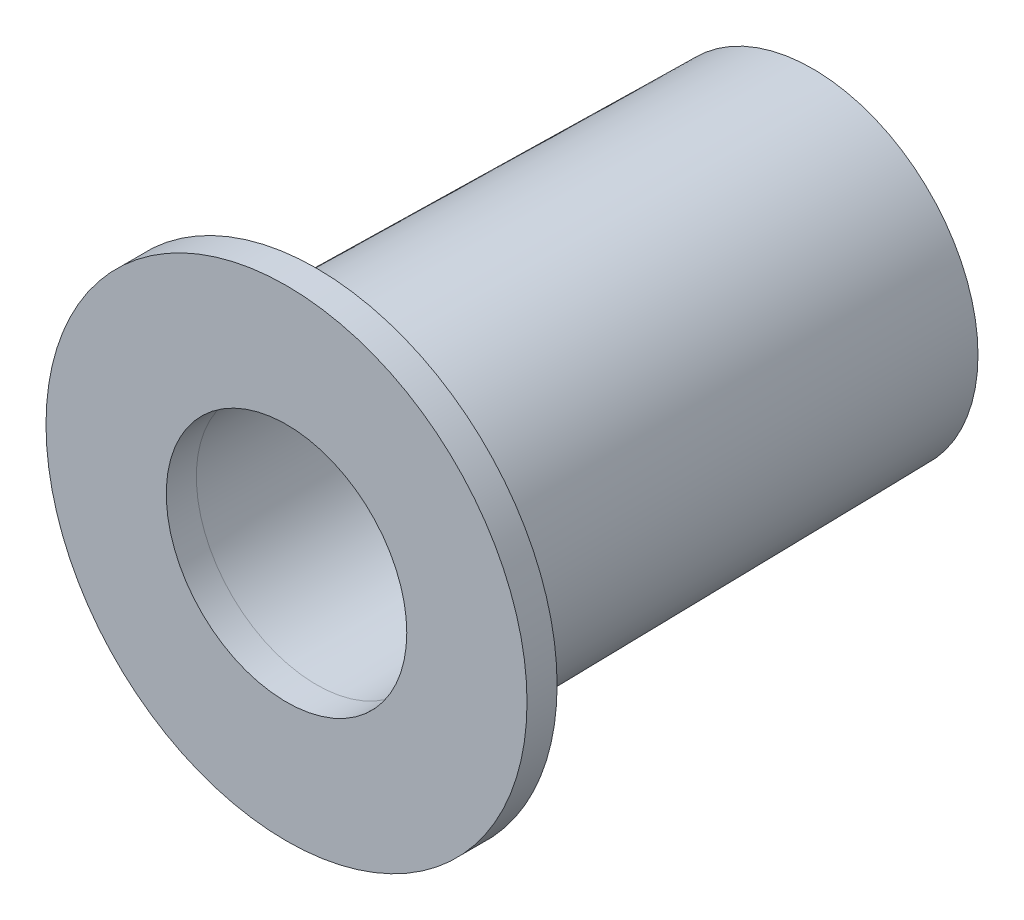
from build123d import *

# Parameters (mm, degrees)
CROQUIS1_R              = 11
CROQUIS3_R              = 11.5
CROQUIS4_R              = 7.5
CROQUIS5_R              = 8
CROQUIS6_R              = 16
CROQUIS6_R_2            = 8
SALIENTE_EXTRUIR1_DEPTH = 2


with BuildPart() as part:
    # Croquis1 → Recubrir1 section 0
    with BuildSketch(Plane.XY):
        Circle(CROQUIS1_R)
    # Croquis3 → Recubrir1 section 1
    with BuildSketch(Plane.XY.offset(33)):
        Circle(CROQUIS3_R)
    loft()

    # Croquis4 → Cortar-Recubrir1 section 0
    with BuildSketch(Plane(origin=(0, 0, 0), x_dir=(-1, 0, 0), z_dir=(0, 0, -1))):
        Circle(CROQUIS4_R)
    # Croquis5 → Cortar-Recubrir1 section 1
    with BuildSketch(Plane.XY.offset(33)):
        Circle(CROQUIS5_R)
    loft(mode=Mode.SUBTRACT)

    # Croquis6 → Saliente-Extruir1 (add)
    with BuildSketch(Plane.XY.offset(33)):
        Circle(CROQUIS6_R)
        Circle(CROQUIS6_R_2, mode=Mode.SUBTRACT)
    extrude(amount=SALIENTE_EXTRUIR1_DEPTH)


solid = part.part
